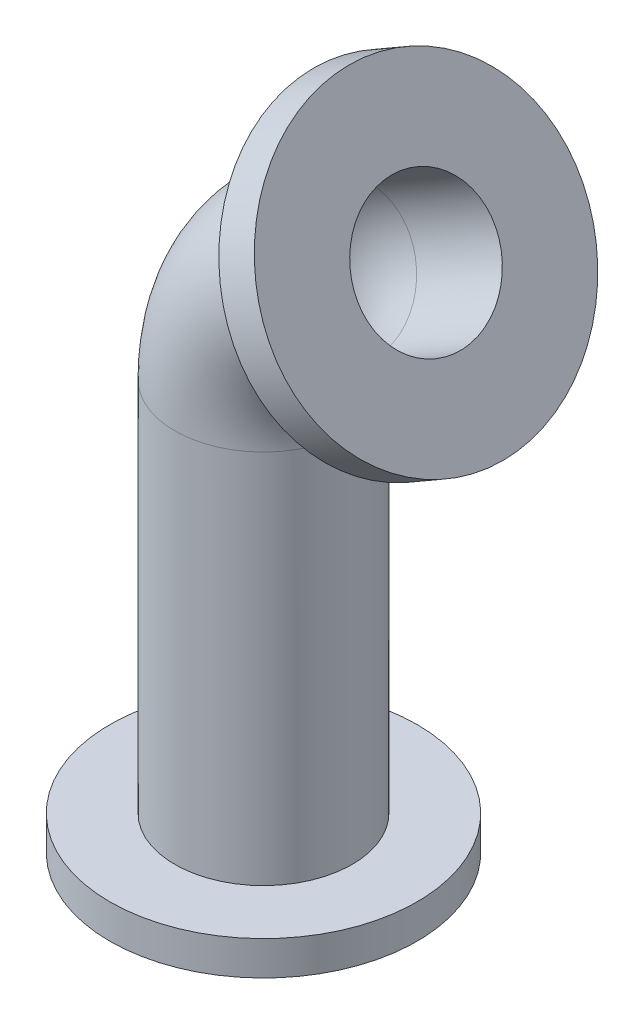
from build123d import *

# Parameters (mm, degrees)
SKIZZE2_R                       = 26
SKIZZE2_R_2                     = 20
SKIZZE3_R                       = 45
SKIZZE3_R_2                     = 26
AUFSATZ_LINEAR_AUSTRAGEN1_DEPTH = 10
SKIZZE4_R                       = 45
SKIZZE4_R_2                     = 26
AUFSATZ_LINEAR_AUSTRAGEN2_DEPTH = 12


with BuildPart() as part:
    # Austragung1: sweep along a path in Skizze1
    with BuildLine(Plane.XY) as austragung1_path:
        Line((0, 0), (0, 120))
        ThreePointArc((0, 120), (6.02885683, 142.5), (22.5, 158.97114317))
        Line((22.5, 158.97114317), (47.61473671, 173.47114317))
    # Skizze2 → Austragung1 (sweep)
    with BuildSketch(Plane(origin=(0, 0, 0), x_dir=(1, 0, 0), z_dir=(0, 1, 0))):
        Circle(SKIZZE2_R)
        Circle(SKIZZE2_R_2, mode=Mode.SUBTRACT)
    sweep(path=austragung1_path.line)

    # Skizze3 → Aufsatz-Linear austragen1 (add)
    with BuildSketch(Plane.XZ):
        with Locations(Location((0, 0, 0), (0, 0, 270))):  # turned: the seam where the file's is
            Circle(SKIZZE3_R)
        with Locations(Location((0, 0, 0), (0, 0, 270))):  # turned: the seam where the file's is
            Circle(SKIZZE3_R_2, mode=Mode.SUBTRACT)
    extrude(amount=-AUFSATZ_LINEAR_AUSTRAGEN1_DEPTH)

    # Skizze4 → Aufsatz-Linear austragen2 (add)
    with BuildSketch(Plane(origin=(110.826260937, 63.985571585, 0), x_dir=(0, 0, -1), z_dir=(0.866025404, 0.5, 0))):
        with Locations(Location((0, 126.423048454, 0), (0, 0, 90))):  # turned: the seam where the file's is
            Circle(SKIZZE4_R)
        with Locations(Location((0, 126.423048454, 0), (0, 0, 90))):  # turned: the seam where the file's is
            Circle(SKIZZE4_R_2, mode=Mode.SUBTRACT)
    extrude(amount=-AUFSATZ_LINEAR_AUSTRAGEN2_DEPTH)


solid = part.part
